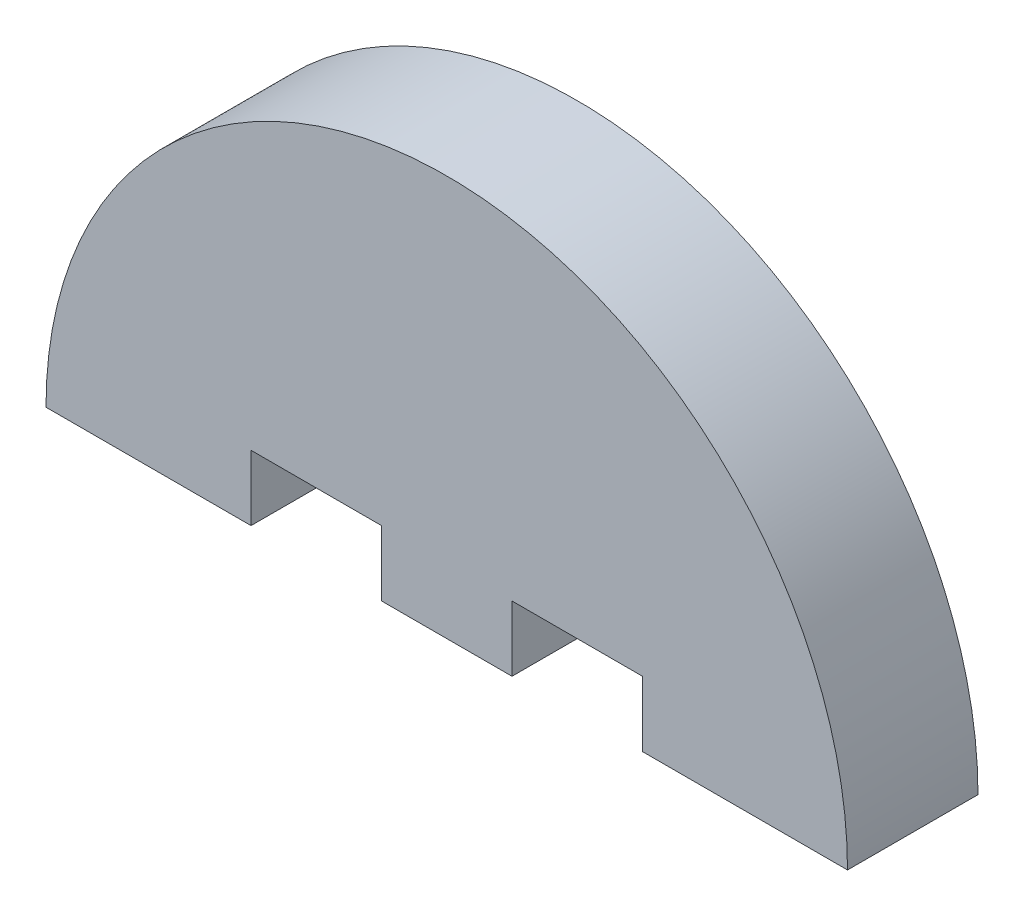
from build123d import *

# Parameters (mm, degrees)
BOSS_EXTRUDE1_DEPTH = 6


with BuildPart() as part:
    # Model → Boss-Extrude1 (new body)
    with BuildSketch(Plane.XY):
        with BuildLine():
            Line((3624.683047417, 1289.903027574), (3615.254475988, 1289.903027574))
            Line((3615.254475988, 1289.903027574), (3615.254475988, 1292.903027574))
            Line((3615.254475988, 1292.903027574), (3609.254475988, 1292.903027574))
            Line((3609.254475988, 1292.903027574), (3609.254475988, 1289.903027574))
            Line((3609.254475988, 1289.903027574), (3603.254475988, 1289.903027574))
            Line((3603.254475988, 1289.903027574), (3603.254475988, 1292.903027574))
            Line((3603.254475988, 1292.903027574), (3597.254475988, 1292.903027574))
            Line((3597.254475988, 1292.903027574), (3597.254475988, 1289.903027574))
            Line((3597.254475988, 1289.903027574), (3587.82590456, 1289.903027574))
            ThreePointArc((3587.82590456, 1289.903027574), (3606.254475988, 1308.331599003), (3624.683047417, 1289.903027574))
        make_face()
    extrude(amount=BOSS_EXTRUDE1_DEPTH)


solid = part.part
